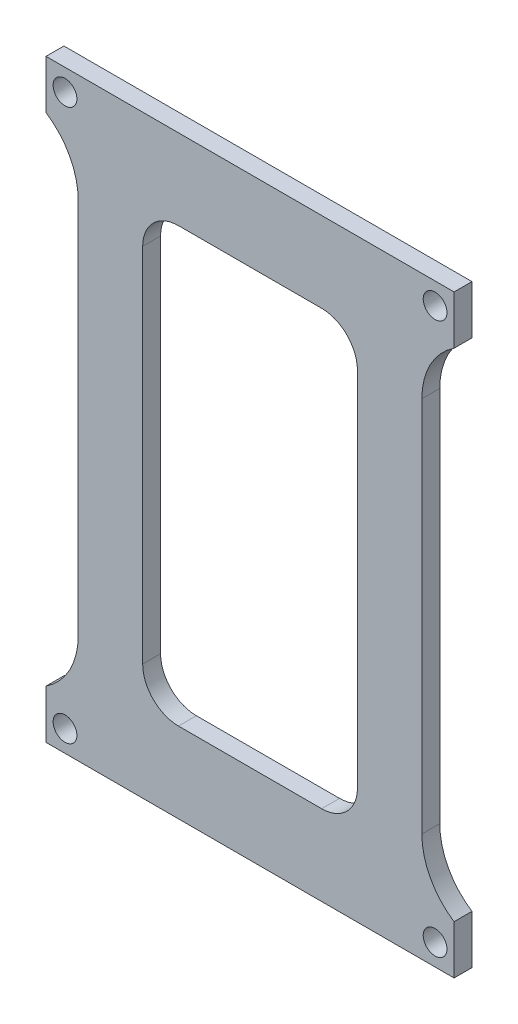
from build123d import *

# Parameters (mm, degrees)
ESQUISSE1_R             = 1.66
BOSS_EXTRU_1_DEPTH      = 2.5
ESQUISSE2_W             = 13.135596865
ESQUISSE2_H             = 97.305440857
ENL_V_MAT_EXTRU_1_DEPTH = 3.5


with BuildPart() as part:
    # Esquisse1 → Boss.-Extru.1 (new body)
    with BuildSketch(Plane.XY):
        with BuildLine():
            Line((-29.728572008, 42.160761401), (-21.428572008, 42.160761401))
            Line((-21.428572008, 42.160761401), (21.971427992, 42.160761401))
            Line((21.971427992, 42.160761401), (30.271427992, 42.160761401))
            Line((30.271427992, 42.160761401), (30.271427992, 36.160761401))
            ThreePointArc((30.271427992, 36.160761401), (25.904827727, 32.472835586), (24.271427992, 26.995610011))
            Line((24.271427992, 26.995610011), (24.271427992, -25.67408721))
            ThreePointArc((24.271427992, -25.67408721), (25.904827727, -31.151312785), (30.271427992, -34.839238599))
            Line((30.271427992, -34.839238599), (30.271427992, -40.839238599))
            Line((30.271427992, -40.839238599), (21.971427992, -40.839238599))
            Line((21.971427992, -40.839238599), (-21.428572008, -40.839238599))
            Line((-21.428572008, -40.839238599), (-29.728572008, -40.839238599))
            Line((-29.728572008, -40.839238599), (-29.728572008, -34.839238599))
            ThreePointArc((-29.728572008, -34.839238599), (-25.361971742, -31.151312785), (-23.728572008, -25.67408721))
            Line((-23.728572008, -25.67408721), (-23.728572008, 26.995610011))
            ThreePointArc((-23.728572008, 26.995610011), (-25.361971742, 32.472835586), (-29.728572008, 36.160761401))
            Line((-29.728572008, 36.160761401), (-29.728572008, 42.160761401))
        make_face()
        with Locations((-25.578572008, 39.160761401)):
            Circle(ESQUISSE1_R, mode=Mode.SUBTRACT)
        with Locations((26.121427992, 39.160761401)):
            Circle(ESQUISSE1_R, mode=Mode.SUBTRACT)
        with Locations((-25.578572008, -37.839238599)):
            Circle(ESQUISSE1_R, mode=Mode.SUBTRACT)
        with Locations((26.121427992, -37.839238599)):
            Circle(ESQUISSE1_R, mode=Mode.SUBTRACT)
        with BuildLine():
            Line((-9.728572008, 30.929161254), (10.271427992, 30.929161254))
            ThreePointArc((10.271427992, 30.929161254), (13.806961898, 29.46469516), (15.271427992, 25.929161254))
            Line((15.271427992, 25.929161254), (15.271427992, -24.607638453))
            ThreePointArc((15.271427992, -24.607638453), (13.806961898, -28.143172359), (10.271427992, -29.607638453))
            Line((10.271427992, -29.607638453), (-9.728572008, -29.607638453))
            ThreePointArc((-9.728572008, -29.607638453), (-13.264105914, -28.143172359), (-14.728572008, -24.607638453))
            Line((-14.728572008, -24.607638453), (-14.728572008, 25.929161254))
            ThreePointArc((-14.728572008, 25.929161254), (-13.264105914, 29.46469516), (-9.728572008, 30.929161254))
        make_face(mode=Mode.SUBTRACT)
    extrude(amount=BOSS_EXTRU_1_DEPTH)

    # Esquisse2 → Enlèv. mat.-Extru.1 (cut, through all)
    with BuildSketch(Plane(origin=(0, 0, 0), x_dir=(-1, 0, 0), z_dir=(0, 0, -1))):
        with Locations((-35.339226425, 0.262800476)):
            Rectangle(ESQUISSE2_W, ESQUISSE2_H)
        with Locations((34.79637044, 0.262800476)):
            Rectangle(ESQUISSE2_W, ESQUISSE2_H)
    extrude(amount=-ENL_V_MAT_EXTRU_1_DEPTH, mode=Mode.SUBTRACT)


solid = part.part
